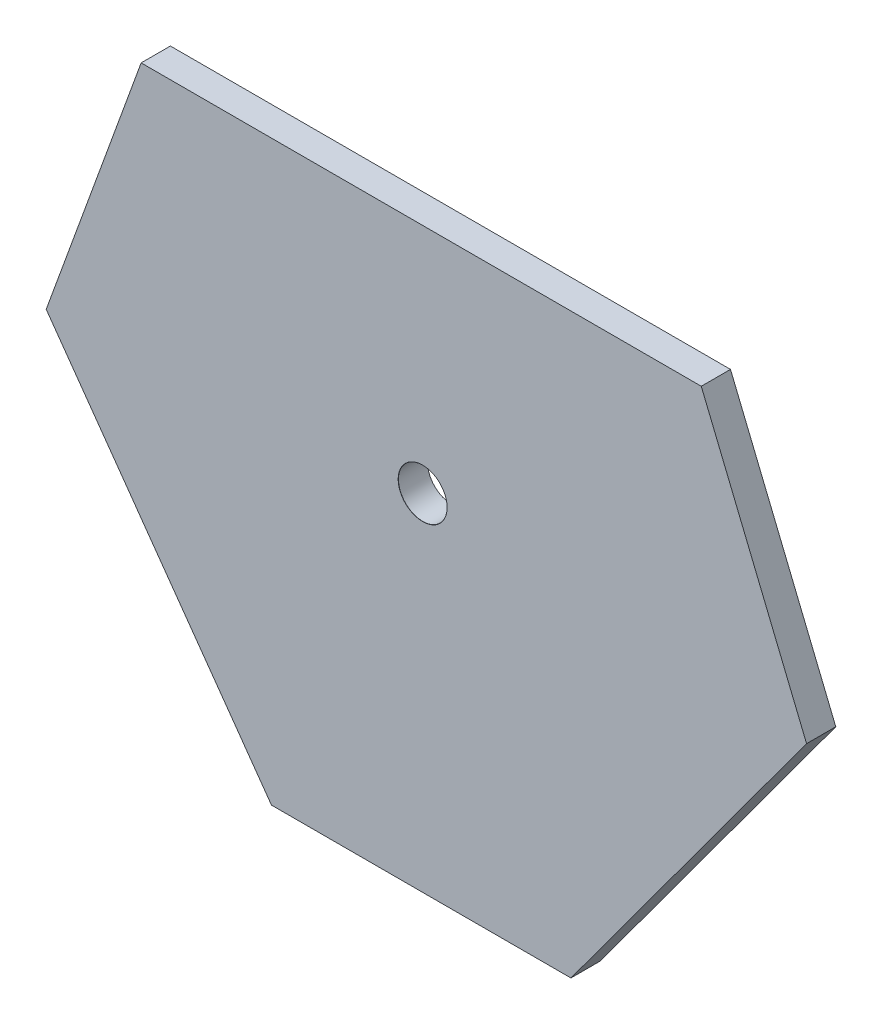
from build123d import *

# Parameters (mm, degrees)
BOSS_EXTRUDE1_DEPTH              = 6
F_10_0MM_DOWEL_HOLE2_D           = 10
F_10_0MM_DOWEL_HOLE2_DEPTH       = 50
F_10_0MM_DOWEL_HOLE2_CSINK_D     = 10.05
F_10_0MM_DOWEL_HOLE2_CSINK_ANGLE = 90
F_10_0MM_DOWEL_HOLE2_TIP         = 3.004303095


with BuildPart() as part:
    # Sketch1 → Boss-Extrude1 (new body)
    with BuildSketch(Plane.XY):
        Polygon((-47.927135712, -8.080790765), (13.552864288, -8.080790765), (61.932230114, 57.778577521), (40.312864288, 110.519482152), (-74.687135712, 110.519482152), (-94.182283881, 56.957002767), align=None)
    extrude(amount=BOSS_EXTRUDE1_DEPTH)

    # Ø10.0mm Dowel Hole2
    with Locations(Plane.XY.offset(6)):
        with Locations((-16.890604688, 62.873141165)):
            CounterSinkHole(F_10_0MM_DOWEL_HOLE2_D / 2, F_10_0MM_DOWEL_HOLE2_CSINK_D / 2, depth=F_10_0MM_DOWEL_HOLE2_DEPTH, counter_sink_angle=F_10_0MM_DOWEL_HOLE2_CSINK_ANGLE)
            with Locations((0, 0, -(F_10_0MM_DOWEL_HOLE2_DEPTH + F_10_0MM_DOWEL_HOLE2_TIP / 2))):  # 118° drill point
                Cone(0, F_10_0MM_DOWEL_HOLE2_D / 2, F_10_0MM_DOWEL_HOLE2_TIP, mode=Mode.SUBTRACT)


solid = part.part
